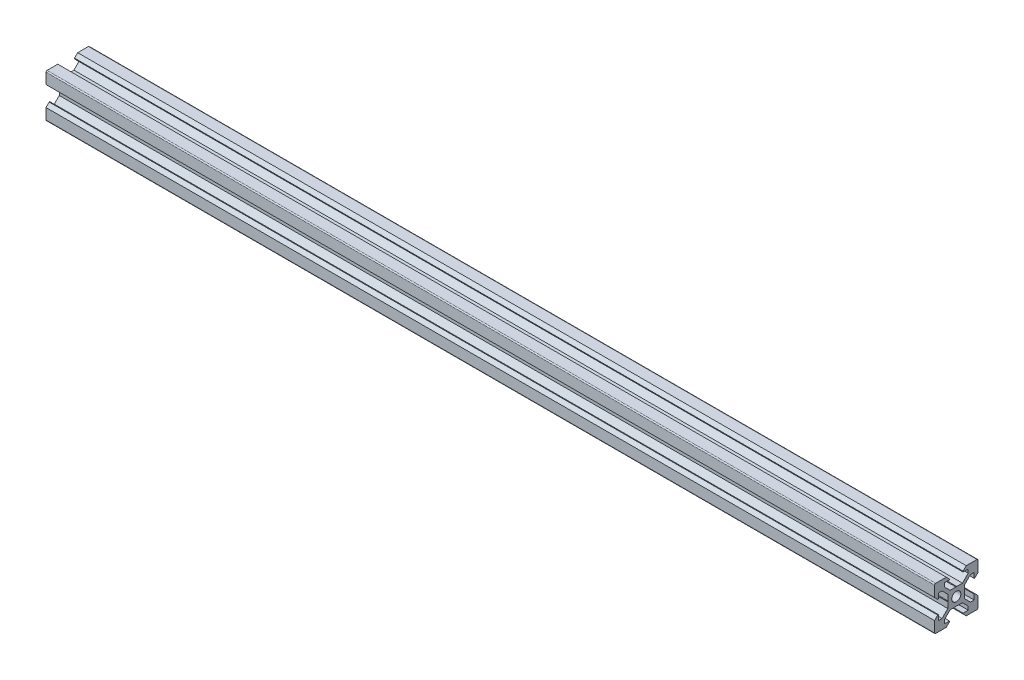
from build123d import *

# Parameters (mm, degrees)
SKETCH1_R           = 2.1
BOSS_EXTRUDE1_DEPTH = 409


with BuildPart() as part:
    # Sketch1 → Boss-Extrude1 (new body)
    with BuildSketch(Plane(origin=(10, 0, 0), x_dir=(0, -1, 0), z_dir=(-1, 0, 0))):
        with BuildLine():
            Line((-10, -534.5), (-10, -539.42))
            Line((-10, -539.42), (-8.545, -540.875))
            Line((-8.545, -540.875), (-8.2, -540.875))
            Line((-8.2, -540.875), (-8.2, -538.5))
            Line((-8.2, -538.5), (-6.560660172, -538.5))
            Line((-6.560660172, -538.5), (-3.9, -541.160660172))
            Line((-3.9, -541.160660172), (-3.9, -543.79))
            Line((-3.9, -543.79), (-3.69, -544))
            Line((-3.69, -544), (-3.9, -544.21))
            Line((-3.9, -544.21), (-3.9, -546.839339828))
            Line((-3.9, -546.839339828), (-6.560660172, -549.5))
            Line((-6.560660172, -549.5), (-8.2, -549.5))
            Line((-8.2, -549.5), (-8.2, -547.125))
            Line((-8.2, -547.125), (-8.545, -547.125))
            Line((-8.545, -547.125), (-10, -548.58))
            Line((-10, -548.58), (-10, -553.5))
            ThreePointArc((-10, -553.5), (-9.853553391, -553.853553391), (-9.5, -554))
            Line((-9.5, -554), (-4.58, -554))
            Line((-4.58, -554), (-3.125, -552.545))
            Line((-3.125, -552.545), (-3.125, -552.2))
            Line((-3.125, -552.2), (-5.5, -552.2))
            Line((-5.5, -552.2), (-5.5, -550.560660172))
            Line((-5.5, -550.560660172), (-2.839339828, -547.9))
            Line((-2.839339828, -547.9), (-0.21, -547.9))
            Line((-0.21, -547.9), (0, -547.69))
            Line((0, -547.69), (0.21, -547.9))
            Line((0.21, -547.9), (2.839339828, -547.9))
            Line((2.839339828, -547.9), (5.5, -550.560660172))
            Line((5.5, -550.560660172), (5.5, -552.2))
            Line((5.5, -552.2), (3.125, -552.2))
            Line((3.125, -552.2), (3.125, -552.545))
            Line((3.125, -552.545), (4.58, -554))
            Line((4.58, -554), (9.5, -554))
            ThreePointArc((9.5, -554), (9.853553391, -553.853553391), (10, -553.5))
            Line((10, -553.5), (10, -548.58))
            Line((10, -548.58), (8.545, -547.125))
            Line((8.545, -547.125), (8.2, -547.125))
            Line((8.2, -547.125), (8.2, -549.5))
            Line((8.2, -549.5), (6.560660172, -549.5))
            Line((6.560660172, -549.5), (3.9, -546.839339828))
            Line((3.9, -546.839339828), (3.9, -544.21))
            Line((3.9, -544.21), (3.69, -544))
            Line((3.69, -544), (3.9, -543.79))
            Line((3.9, -543.79), (3.9, -541.160660171))
            Line((3.9, -541.160660171), (6.560660171, -538.5))
            Line((6.560660171, -538.5), (8.2, -538.5))
            Line((8.2, -538.5), (8.2, -540.875))
            Line((8.2, -540.875), (8.545, -540.875))
            Line((8.545, -540.875), (10, -539.42))
            Line((10, -539.42), (10, -534.5))
            ThreePointArc((10, -534.5), (9.853553391, -534.146446609), (9.5, -534))
            Line((9.5, -534), (4.58, -534))
            Line((4.58, -534), (3.125, -535.455))
            Line((3.125, -535.455), (3.125, -535.8))
            Line((3.125, -535.8), (5.5, -535.8))
            Line((5.5, -535.8), (5.5, -537.439339828))
            Line((5.5, -537.439339828), (2.839339828, -540.1))
            Line((2.839339828, -540.1), (0.21, -540.1))
            Line((0.21, -540.1), (0, -540.31))
            Line((0, -540.31), (-0.21, -540.1))
            Line((-0.21, -540.1), (-2.839339828, -540.1))
            Line((-2.839339828, -540.1), (-5.5, -537.439339828))
            Line((-5.5, -537.439339828), (-5.5, -535.8))
            Line((-5.5, -535.8), (-3.125, -535.8))
            Line((-3.125, -535.8), (-3.125, -535.455))
            Line((-3.125, -535.455), (-4.58, -534))
            Line((-4.58, -534), (-9.5, -534))
            ThreePointArc((-9.5, -534), (-9.853553391, -534.146446609), (-10, -534.5))
        make_face()
        with Locations((0, -544)):
            Circle(SKETCH1_R, mode=Mode.SUBTRACT)
    extrude(amount=-BOSS_EXTRUDE1_DEPTH)


solid = part.part
